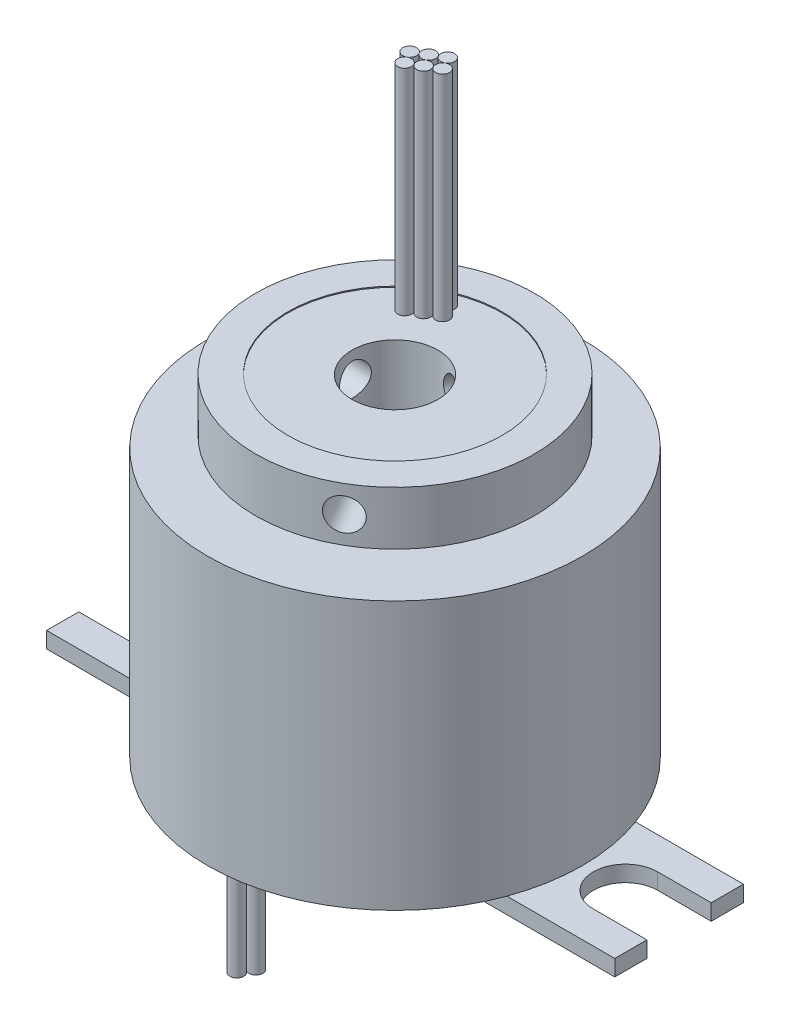
from build123d import *

# Parameters (mm, degrees)
SKETCH_1_R               = 17.5
EXTRUDE_1_DEPTH          = 25
SKETCH_2_R               = 10
EXTRUDE_2_DEPTH          = 1
SKETCH_3_R               = 13
EXTRUDE_3_DEPTH          = 5
SKETCH_4_R               = 4
CUT_EXTRUDE_1_DEPTH      = 47
SKETCH_5_R               = 1.5
CUT_EXTRUDE_2_DEPTH      = 47
PATTERN_CIRCULAR_1_COUNT = 3
SKETCH_8_R               = 10
CUT_EXTRUDE_3_DEPTH      = 0.1
SKETCH_9_R               = 0.645
EXTRUDE_4_DEPTH          = 20
SKETCH_10_R              = 0.645
EXTRUDE_5_DEPTH          = 10
EXTRUDE_6_DEPTH          = 1.5


with BuildPart() as part:
    # 草图1 → 凸台-拉伸1 (new body)
    with BuildSketch(Plane(origin=(0, 0, 0), x_dir=(1, 0, 0), z_dir=(0, 1, 0))):
        Circle(SKETCH_1_R)
    extrude(amount=EXTRUDE_1_DEPTH)

    # 草图2 → 凸台-拉伸2 (add)
    with BuildSketch(Plane(origin=(0, 25, 0), x_dir=(1, 0, 0), z_dir=(0, 1, 0))):
        Circle(SKETCH_2_R)
    extrude(amount=EXTRUDE_2_DEPTH)

    # 草图3 → 凸台-拉伸3 (add)
    with BuildSketch(Plane(origin=(0, 26, 0), x_dir=(1, 0, 0), z_dir=(0, 1, 0))):
        Circle(SKETCH_3_R)
    extrude(amount=EXTRUDE_3_DEPTH)

    # 草图4 → 切除-拉伸1 (cut)
    with BuildSketch(Plane(origin=(0, 31, 0), x_dir=(1, 0, 0), z_dir=(0, 1, 0))):
        Circle(SKETCH_4_R)
    extrude(amount=-CUT_EXTRUDE_1_DEPTH, mode=Mode.SUBTRACT)

    # 草图5 → 切除-拉伸2 (cut)
    with BuildSketch(Plane(origin=(0, 0, 0), x_dir=(0, 0, -1), z_dir=(1, 0, 0))):
        with Locations((0, 28.5)):
            Circle(SKETCH_5_R)
    cut_extrude_2 = extrude(amount=-CUT_EXTRUDE_2_DEPTH, mode=Mode.SUBTRACT)

    # 阵列(圆周)1: 切除-拉伸2 ×3 about axis
    pattern_circular_1_axis = Axis((0, 39.080777009, 0), (0, -1, 0))
    for i in range(1, PATTERN_CIRCULAR_1_COUNT):
        add(cut_extrude_2.rotate(pattern_circular_1_axis, i * 360 / PATTERN_CIRCULAR_1_COUNT), mode=Mode.SUBTRACT)

    # 草图8 → 切除-拉伸3 (cut)
    with BuildSketch(Plane(origin=(0, 31, 0), x_dir=(1, 0, 0), z_dir=(0, 1, 0))):
        Circle(SKETCH_8_R)
    extrude(amount=-CUT_EXTRUDE_3_DEPTH, mode=Mode.SUBTRACT)

    # 草图9 → 凸台-拉伸4 (add)
    with BuildSketch(Plane(origin=(0, 30.9, 0), x_dir=(1, 0, 0), z_dir=(0, 1, 0))):
        with Locations((-5.423552013, 6.793867644)):
            Circle(SKETCH_9_R)
        with Locations((-4.297718988, 7.443867644)):
            Circle(SKETCH_9_R)
        with Locations((-3.171885963, 8.093867644)):
            Circle(SKETCH_9_R)
        with Locations((-4.773552013, 5.668034619)):
            Circle(SKETCH_9_R)
        with Locations((-3.647718988, 6.318034619)):
            Circle(SKETCH_9_R)
        with Locations((-2.521885963, 6.968034619)):
            Circle(SKETCH_9_R)
    extrude(amount=EXTRUDE_4_DEPTH)

    # 草图10 → 凸台-拉伸5 (add)
    with BuildSketch(Plane.XZ):
        with Locations((0.65, 13.624722325)):
            Circle(SKETCH_10_R)
        with Locations((-0.65, 13.624722325)):
            Circle(SKETCH_10_R)
        with Locations((0, 14.75055535)):
            Circle(SKETCH_10_R)
        with Locations((0.65, -14.375277675)):
            Circle(SKETCH_10_R)
        with Locations((-0.65, -14.375277675)):
            Circle(SKETCH_10_R)
        with Locations((0, -13.24944465)):
            Circle(SKETCH_10_R)
    extrude(amount=EXTRUDE_5_DEPTH)

    # 草图11 → 凸台-拉伸6 (add)
    with BuildSketch(Plane.XZ):
        with BuildLine():
            Line((-26.5, 3), (-21.5, 3))
            ThreePointArc((-21.5, 3), (-18.5, 0), (-21.5, -3))
            Line((-21.5, -3), (-26.5, -3))
            Line((-26.5, -3), (-26.5, -6))
            Line((-26.5, -6), (-11.5, -6))
            Line((-11.5, -6), (-11.5, 6))
            Line((-11.5, 6), (-26.5, 6))
            Line((-26.5, 6), (-26.5, 3))
        make_face()
        with BuildLine():
            Line((11.5, -6), (11.5, 6))
            Line((11.5, 6), (26.5, 6))
            Line((26.5, 6), (26.5, 3))
            Line((26.5, 3), (21.5, 3))
            ThreePointArc((21.5, 3), (18.5, 0), (21.5, -3))
            Line((21.5, -3), (26.5, -3))
            Line((26.5, -3), (26.5, -6))
            Line((26.5, -6), (11.5, -6))
        make_face()
    extrude(amount=EXTRUDE_6_DEPTH)


solid = part.part
